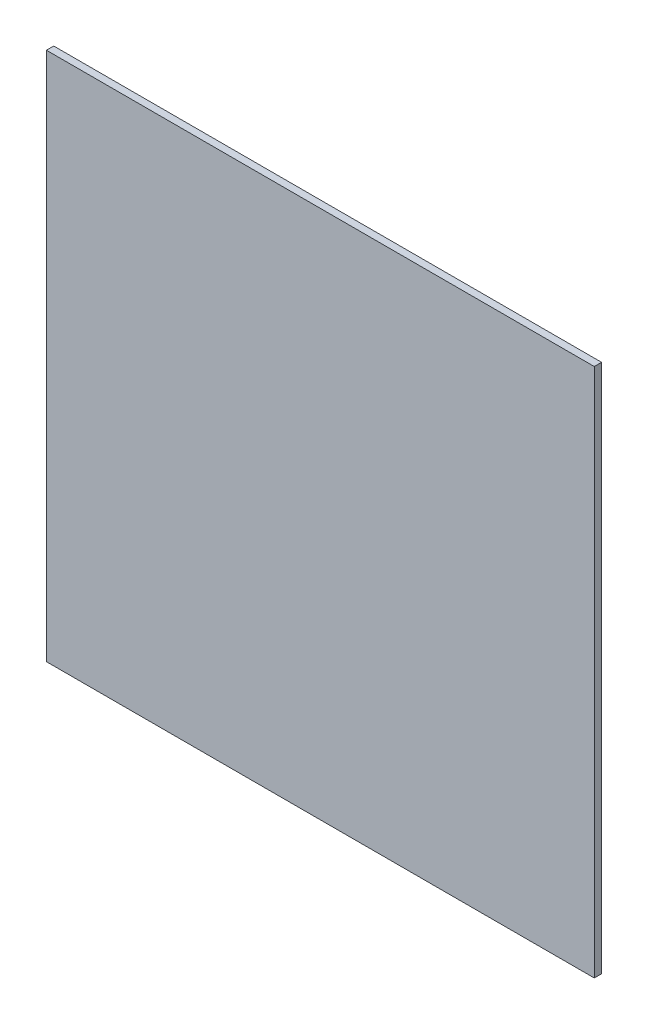
from build123d import *

# Parameters (mm, degrees)
SKETCH1_W           = 300
SKETCH1_H           = 300
BOSS_EXTRUDE1_DEPTH = 4
SKETCH2_R           = 1.5
CUT_EXTRUDE1_DEPTH  = 25
SKETCH3_W           = 300
SKETCH3_H           = 10
CUT_EXTRUDE2_DEPTH  = 5
SKETCH4_R           = 1.5
CUT_EXTRUDE3_DEPTH  = 25


with BuildPart() as part:
    # Sketch1 → Boss-Extrude1 (new body)
    with BuildSketch(Plane.XY):
        with Locations((150, 150)):
            Rectangle(SKETCH1_W, SKETCH1_H)
    extrude(amount=BOSS_EXTRUDE1_DEPTH)

    # Sketch2 → Cut-Extrude1 (cut)
    with BuildSketch(Plane(origin=(0, 0, 0), x_dir=(-1, 0, 0), z_dir=(0, -1, 0))):
        with Locations((-50, -2)):
            Circle(SKETCH2_R)
        with Locations((-250, -2)):
            Circle(SKETCH2_R)
        with Locations((-150, -2)):
            Circle(SKETCH2_R)
    extrude(amount=-CUT_EXTRUDE1_DEPTH, mode=Mode.SUBTRACT)

    # Sketch3 → Cut-Extrude2 (cut, through all)
    with BuildSketch(Plane(origin=(0, 0, 0), x_dir=(-1, 0, 0), z_dir=(0, 0, -1))):
        with Locations((-150, 295)):
            Rectangle(SKETCH3_W, SKETCH3_H)
    extrude(amount=-CUT_EXTRUDE2_DEPTH, mode=Mode.SUBTRACT)

    # Sketch4 → Cut-Extrude3 (cut)
    with BuildSketch(Plane.ZY):
        with Locations((2, 245)):
            Circle(SKETCH4_R)
        with Locations((2, 45)):
            Circle(SKETCH4_R)
        with Locations((2, 145)):
            Circle(SKETCH4_R)
    extrude(amount=-CUT_EXTRUDE3_DEPTH, mode=Mode.SUBTRACT)


solid = part.part
